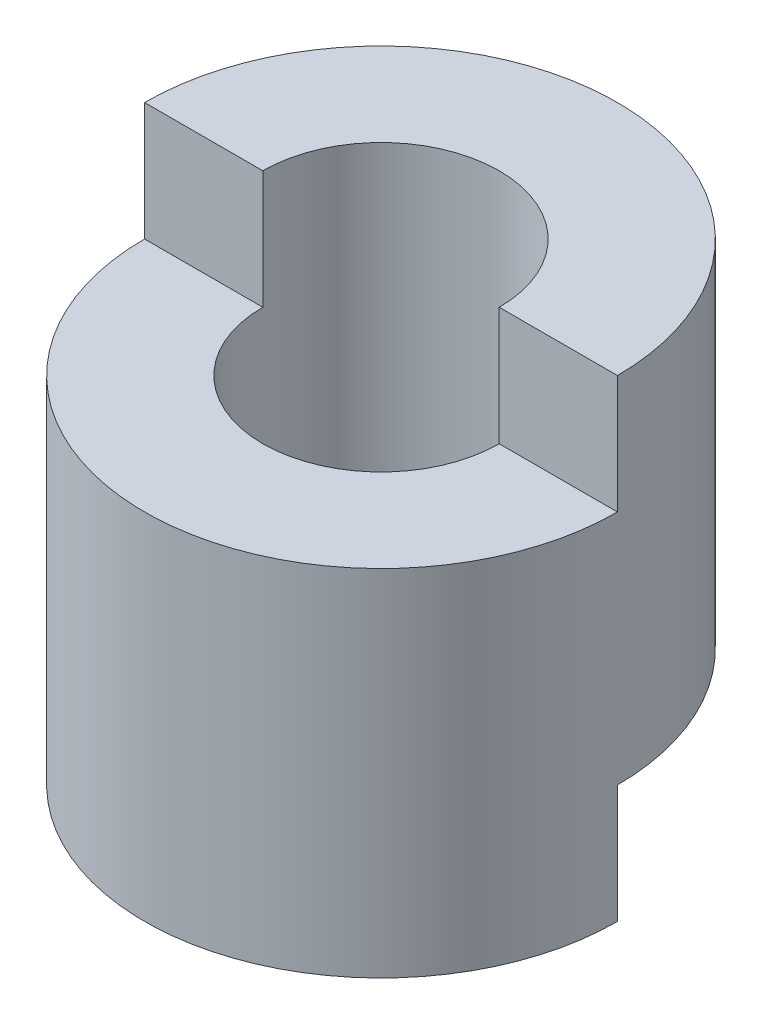
from build123d import *

# Parameters (mm, degrees)
SKETCH1_W          = 10
SKETCH1_H          = 20
SKETCH2_R          = 5
CUT_EXTRUDE1_DEPTH = 20
CUT_EXTRUDE2_DEPTH = 5
CUT_EXTRUDE3_DEPTH = 5


with BuildPart() as part:
    # Sketch1 → Revolve1 (revolve)
    with BuildSketch(Plane.XY):
        with Locations((5, 10)):
            Rectangle(SKETCH1_W, SKETCH1_H)
    revolve(axis=Axis((0, 0, 0), (0, 1, 0)))

    # Sketch2 → Cut-Extrude1 (cut)
    with BuildSketch(Plane(origin=(0, 20, 0), x_dir=(1, 0, 0), z_dir=(0, 1, 0))):
        Circle(SKETCH2_R)
    extrude(amount=-CUT_EXTRUDE1_DEPTH, mode=Mode.SUBTRACT)

    # Sketch3 → Cut-Extrude2 (cut)
    with BuildSketch(Plane(origin=(0, 20, 0), x_dir=(1, 0, 0), z_dir=(0, 1, 0))):
        with BuildLine():
            Line((-10, 0), (-5, 0))
            ThreePointArc((-5, 0), (0, -5), (5, 0))
            Line((5, 0), (10, 0))
            ThreePointArc((10, 0), (0, -10), (-10, 0))
        make_face()
    extrude(amount=-CUT_EXTRUDE2_DEPTH, mode=Mode.SUBTRACT)

    # Sketch4 → Cut-Extrude3 (cut)
    with BuildSketch(Plane(origin=(0, 0, 0), x_dir=(-1, 0, 0), z_dir=(0, -1, 0))):
        with BuildLine():
            Line((10, 0), (5, 0))
            ThreePointArc((5, 0), (0, 5), (-5, 0))
            Line((-5, 0), (-10, 0))
            ThreePointArc((-10, 0), (0, 10), (10, 0))
        make_face()
    extrude(amount=-CUT_EXTRUDE3_DEPTH, mode=Mode.SUBTRACT)


solid = part.part
